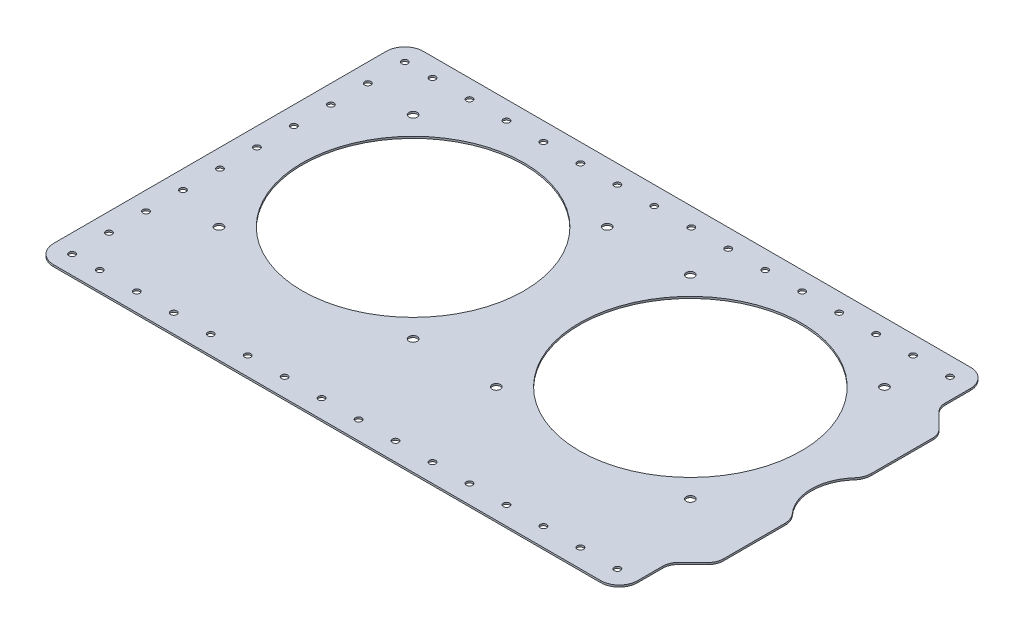
from build123d import *

# Parameters (mm, degrees)
SKETCH1_W                      = 329
SKETCH1_H                      = 200
BOSS_EXTRUDE1_DEPTH            = 1
CUT_EXTRUDE1_DEPTH             = 2
FILLET1_R                      = 8
FILLET2_R                      = 10
SKETCH3_R                      = 1.7
CUT_EXTRUDE2_DEPTH             = 2
M3_CLEARANCE_HOLE1_AT_2_COUNT  = 2
M3_CLEARANCE_HOLE1_AT_2_PITCH  = 20
M3_CLEARANCE_HOLE1_AT_3_COUNT  = 2
M3_CLEARANCE_HOLE1_AT_3_PITCH  = 40
M3_CLEARANCE_HOLE1_AT_4_COUNT  = 2
M3_CLEARANCE_HOLE1_AT_4_PITCH  = 60
M3_CLEARANCE_HOLE1_AT_5_COUNT  = 2
M3_CLEARANCE_HOLE1_AT_5_PITCH  = 80
M3_CLEARANCE_HOLE1_AT_6_COUNT  = 2
M3_CLEARANCE_HOLE1_AT_6_PITCH  = 100
M3_CLEARANCE_HOLE1_AT_7_COUNT  = 2
M3_CLEARANCE_HOLE1_AT_7_PITCH  = 120
M3_CLEARANCE_HOLE2_AT_2_COUNT  = 2
M3_CLEARANCE_HOLE2_AT_2_PITCH  = 20
M3_CLEARANCE_HOLE2_AT_3_COUNT  = 2
M3_CLEARANCE_HOLE2_AT_3_PITCH  = 40
M3_CLEARANCE_HOLE2_AT_4_COUNT  = 2
M3_CLEARANCE_HOLE2_AT_4_PITCH  = 60
M3_CLEARANCE_HOLE2_AT_5_COUNT  = 2
M3_CLEARANCE_HOLE2_AT_5_PITCH  = 80
M3_CLEARANCE_HOLE2_AT_6_COUNT  = 2
M3_CLEARANCE_HOLE2_AT_6_PITCH  = 100
M3_CLEARANCE_HOLE2_AT_7_COUNT  = 2
M3_CLEARANCE_HOLE2_AT_7_PITCH  = 120
M3_CLEARANCE_HOLE2_AT_8_COUNT  = 2
M3_CLEARANCE_HOLE2_AT_8_PITCH  = 140
M3_CLEARANCE_HOLE2_AT_9_COUNT  = 2
M3_CLEARANCE_HOLE2_AT_9_PITCH  = 160
M3_CLEARANCE_HOLE2_AT_10_COUNT = 2
M3_CLEARANCE_HOLE2_AT_10_PITCH = 180
M3_CLEARANCE_HOLE2_AT_11_COUNT = 2
M3_CLEARANCE_HOLE2_AT_11_PITCH = 200
M3_CLEARANCE_HOLE2_AT_12_COUNT = 2
M3_CLEARANCE_HOLE2_AT_12_PITCH = 220
M3_CLEARANCE_HOLE2_AT_13_COUNT = 2
M3_CLEARANCE_HOLE2_AT_13_PITCH = 240
M3_CLEARANCE_HOLE2_AT_14_COUNT = 2
M3_CLEARANCE_HOLE2_AT_14_PITCH = 260
M3_CLEARANCE_HOLE2_AT_15_COUNT = 2
M3_CLEARANCE_HOLE2_AT_15_PITCH = 280
M3_CLEARANCE_HOLE2_AT_16_COUNT = 2
M3_CLEARANCE_HOLE2_AT_16_PITCH = 332.866339542
M3_CLEARANCE_HOLE2_AT_17_COUNT = 2
M3_CLEARANCE_HOLE2_AT_17_PITCH = 316.227766017
M3_CLEARANCE_HOLE2_AT_18_COUNT = 2
M3_CLEARANCE_HOLE2_AT_18_PITCH = 300
M3_CLEARANCE_HOLE2_AT_19_COUNT = 2
M3_CLEARANCE_HOLE2_AT_19_PITCH = 284.253408071
M3_CLEARANCE_HOLE2_AT_20_COUNT = 2
M3_CLEARANCE_HOLE2_AT_20_PITCH = 269.072480941
M3_CLEARANCE_HOLE2_AT_21_COUNT = 2
M3_CLEARANCE_HOLE2_AT_21_PITCH = 254.558441227
M3_CLEARANCE_HOLE2_AT_22_COUNT = 2
M3_CLEARANCE_HOLE2_AT_22_PITCH = 240.831891576
M3_CLEARANCE_HOLE2_AT_23_COUNT = 2
M3_CLEARANCE_HOLE2_AT_23_PITCH = 228.03508502
M3_CLEARANCE_HOLE2_AT_24_COUNT = 2
M3_CLEARANCE_HOLE2_AT_24_PITCH = 216.333076528
M3_CLEARANCE_HOLE2_AT_25_COUNT = 2
M3_CLEARANCE_HOLE2_AT_25_PITCH = 205.91260282
M3_CLEARANCE_HOLE2_AT_26_COUNT = 2
M3_CLEARANCE_HOLE2_AT_26_PITCH = 196.977156036
M3_CLEARANCE_HOLE2_AT_27_COUNT = 2
M3_CLEARANCE_HOLE2_AT_27_PITCH = 189.73665961
M3_CLEARANCE_HOLE2_AT_28_COUNT = 2
M3_CLEARANCE_HOLE2_AT_28_PITCH = 184.390889146
M3_CLEARANCE_HOLE2_AT_29_COUNT = 2
M3_CLEARANCE_HOLE2_AT_29_PITCH = 181.107702763
M3_CLEARANCE_HOLE2_AT_30_COUNT = 2
M3_CLEARANCE_HOLE2_AT_30_PITCH = 180
SKETCH9_R                      = 25
CUT_EXTRUDE3_DEPTH             = 10
FILLET3_R                      = 10
M4_CLEARANCE_HOLE1_AT_2_COUNT  = 2
M4_CLEARANCE_HOLE1_AT_2_PITCH  = 183.098334236
M4_CLEARANCE_HOLE1_AT_3_COUNT  = 2
M4_CLEARANCE_HOLE1_AT_3_PITCH  = 255
M4_CLEARANCE_HOLE1_AT_4_COUNT  = 2
M4_CLEARANCE_HOLE1_AT_4_PITCH  = 275.771644663
M4_CLEARANCE_HOLE1_AT_5_COUNT  = 2
M4_CLEARANCE_HOLE1_AT_5_PITCH  = 150
M4_CLEARANCE_HOLE1_AT_6_COUNT  = 2
M4_CLEARANCE_HOLE1_AT_6_PITCH  = 105
M4_CLEARANCE_HOLE1_AT_7_COUNT  = 2
M4_CLEARANCE_HOLE1_AT_7_PITCH  = 148.492424049
M4_CLEARANCE_HOLE1_AT_8_COUNT  = 2
M4_CLEARANCE_HOLE1_AT_8_PITCH  = 105
SKETCH12_R                     = 60
CUT_EXTRUDE4_DEPTH             = 10


with BuildPart() as part:
    # Sketch1 → Boss-Extrude1 (new body)
    with BuildSketch(Plane(origin=(0, 0, 0), x_dir=(1, 0, 0), z_dir=(0, 1, 0))):
        Rectangle(SKETCH1_W, SKETCH1_H)
    extrude(amount=BOSS_EXTRUDE1_DEPTH)

    # Sketch2 → Cut-Extrude1 (cut, through all)
    with BuildSketch(Plane(origin=(0, 0, 0), x_dir=(-1, 0, 0), z_dir=(0, -1, 0))):
        Polygon((-164.5, -60), (-151.5, -73), (-151.5, -100), (-164.5, -100), align=None)
        Polygon((-151.5, 100), (-164.5, 100), (-164.5, 60), (-151.5, 73), align=None)
    extrude(amount=-CUT_EXTRUDE1_DEPTH, mode=Mode.SUBTRACT)

    # Fillet1
    fillet1_edges = [part.edges().sort_by_distance(p)[0] for p in [
        (164.5, 0.5, 60),
        (151.5, 0.5, 73),
        (151.5, 0.5, -73),
        (164.5, 0.5, -60),
    ]]
    fillet(fillet1_edges, radius=FILLET1_R)

    # Fillet2
    fillet2_edges = [part.edges().sort_by_distance(p)[0] for p in [
        (151.5, 0.5, 100),
        (151.5, 0.5, -100),
        (-164.5, 0.5, 100),
        (-164.5, 0.5, -100),
    ]]
    fillet(fillet2_edges, radius=FILLET2_R)

    # Sketch3 → Cut-Extrude2 (cut, through all)
    with BuildSketch(Plane.XZ):
        with Locations((-154.5, -70)):
            Circle(SKETCH3_R)
        with Locations((-154.5, -90)):
            Circle(SKETCH3_R)
        with Locations((-154.5, 70)):
            Circle(SKETCH3_R)
        with Locations((-154.5, 90)):
            Circle(SKETCH3_R)
    extrude(amount=-CUT_EXTRUDE2_DEPTH, mode=Mode.SUBTRACT)

    # Sketch6 → M3 Clearance Hole1 (revolve, cut)
    with BuildSketch(Plane(origin=(-154.5, 0, 70), x_dir=(0, 0, -1), z_dir=(1, 0, 0))):
        Polygon((0, 0), (0, 1), (1.7, 1), (1.7, 0.025), (1.725, 0), align=None)
    m3_clearance_hole1 = revolve(axis=Axis((-154.5, -6.35, 70), (0, 1, 0)), mode=Mode.SUBTRACT)

    # M3 Clearance Hole1 at 2: M3 Clearance Hole1 ×2
    with Locations(*[(0, 0, -i * M3_CLEARANCE_HOLE1_AT_2_PITCH) for i in range(1, M3_CLEARANCE_HOLE1_AT_2_COUNT)]):
        add(m3_clearance_hole1, mode=Mode.SUBTRACT)

    # M3 Clearance Hole1 at 3: M3 Clearance Hole1 ×2
    with Locations(*[(0, 0, -i * M3_CLEARANCE_HOLE1_AT_3_PITCH) for i in range(1, M3_CLEARANCE_HOLE1_AT_3_COUNT)]):
        add(m3_clearance_hole1, mode=Mode.SUBTRACT)

    # M3 Clearance Hole1 at 4: M3 Clearance Hole1 ×2
    with Locations(*[(0, 0, -i * M3_CLEARANCE_HOLE1_AT_4_PITCH) for i in range(1, M3_CLEARANCE_HOLE1_AT_4_COUNT)]):
        add(m3_clearance_hole1, mode=Mode.SUBTRACT)

    # M3 Clearance Hole1 at 5: M3 Clearance Hole1 ×2
    with Locations(*[(0, 0, -i * M3_CLEARANCE_HOLE1_AT_5_PITCH) for i in range(1, M3_CLEARANCE_HOLE1_AT_5_COUNT)]):
        add(m3_clearance_hole1, mode=Mode.SUBTRACT)

    # M3 Clearance Hole1 at 6: M3 Clearance Hole1 ×2
    with Locations(*[(0, 0, -i * M3_CLEARANCE_HOLE1_AT_6_PITCH) for i in range(1, M3_CLEARANCE_HOLE1_AT_6_COUNT)]):
        add(m3_clearance_hole1, mode=Mode.SUBTRACT)

    # M3 Clearance Hole1 at 7: M3 Clearance Hole1 ×2
    with Locations(*[(0, 0, -i * M3_CLEARANCE_HOLE1_AT_7_PITCH) for i in range(1, M3_CLEARANCE_HOLE1_AT_7_COUNT)]):
        add(m3_clearance_hole1, mode=Mode.SUBTRACT)

    # Sketch8 → M3 Clearance Hole2 (revolve, cut)
    with BuildSketch(Plane(origin=(140.5, 0, -90), x_dir=(0, 0, -1), z_dir=(1, 0, 0))):
        Polygon((0, 0), (0, 1), (1.7, 1), (1.7, 0.025), (1.725, 0), align=None)
    m3_clearance_hole2 = revolve(axis=Axis((140.5, -6.35, -90), (0, 1, 0)), mode=Mode.SUBTRACT)

    # M3 Clearance Hole2 at 2: M3 Clearance Hole2 ×2
    with Locations(*[(-i * M3_CLEARANCE_HOLE2_AT_2_PITCH, 0, 0) for i in range(1, M3_CLEARANCE_HOLE2_AT_2_COUNT)]):
        add(m3_clearance_hole2, mode=Mode.SUBTRACT)

    # M3 Clearance Hole2 at 3: M3 Clearance Hole2 ×2
    with Locations(*[(-i * M3_CLEARANCE_HOLE2_AT_3_PITCH, 0, 0) for i in range(1, M3_CLEARANCE_HOLE2_AT_3_COUNT)]):
        add(m3_clearance_hole2, mode=Mode.SUBTRACT)

    # M3 Clearance Hole2 at 4: M3 Clearance Hole2 ×2
    with Locations(*[(-i * M3_CLEARANCE_HOLE2_AT_4_PITCH, 0, 0) for i in range(1, M3_CLEARANCE_HOLE2_AT_4_COUNT)]):
        add(m3_clearance_hole2, mode=Mode.SUBTRACT)

    # M3 Clearance Hole2 at 5: M3 Clearance Hole2 ×2
    with Locations(*[(-i * M3_CLEARANCE_HOLE2_AT_5_PITCH, 0, 0) for i in range(1, M3_CLEARANCE_HOLE2_AT_5_COUNT)]):
        add(m3_clearance_hole2, mode=Mode.SUBTRACT)

    # M3 Clearance Hole2 at 6: M3 Clearance Hole2 ×2
    with Locations(*[(-i * M3_CLEARANCE_HOLE2_AT_6_PITCH, 0, 0) for i in range(1, M3_CLEARANCE_HOLE2_AT_6_COUNT)]):
        add(m3_clearance_hole2, mode=Mode.SUBTRACT)

    # M3 Clearance Hole2 at 7: M3 Clearance Hole2 ×2
    with Locations(*[(-i * M3_CLEARANCE_HOLE2_AT_7_PITCH, 0, 0) for i in range(1, M3_CLEARANCE_HOLE2_AT_7_COUNT)]):
        add(m3_clearance_hole2, mode=Mode.SUBTRACT)

    # M3 Clearance Hole2 at 8: M3 Clearance Hole2 ×2
    with Locations(*[(-i * M3_CLEARANCE_HOLE2_AT_8_PITCH, 0, 0) for i in range(1, M3_CLEARANCE_HOLE2_AT_8_COUNT)]):
        add(m3_clearance_hole2, mode=Mode.SUBTRACT)

    # M3 Clearance Hole2 at 9: M3 Clearance Hole2 ×2
    with Locations(*[(-i * M3_CLEARANCE_HOLE2_AT_9_PITCH, 0, 0) for i in range(1, M3_CLEARANCE_HOLE2_AT_9_COUNT)]):
        add(m3_clearance_hole2, mode=Mode.SUBTRACT)

    # M3 Clearance Hole2 at 10: M3 Clearance Hole2 ×2
    with Locations(*[(-i * M3_CLEARANCE_HOLE2_AT_10_PITCH, 0, 0) for i in range(1, M3_CLEARANCE_HOLE2_AT_10_COUNT)]):
        add(m3_clearance_hole2, mode=Mode.SUBTRACT)

    # M3 Clearance Hole2 at 11: M3 Clearance Hole2 ×2
    with Locations(*[(-i * M3_CLEARANCE_HOLE2_AT_11_PITCH, 0, 0) for i in range(1, M3_CLEARANCE_HOLE2_AT_11_COUNT)]):
        add(m3_clearance_hole2, mode=Mode.SUBTRACT)

    # M3 Clearance Hole2 at 12: M3 Clearance Hole2 ×2
    with Locations(*[(-i * M3_CLEARANCE_HOLE2_AT_12_PITCH, 0, 0) for i in range(1, M3_CLEARANCE_HOLE2_AT_12_COUNT)]):
        add(m3_clearance_hole2, mode=Mode.SUBTRACT)

    # M3 Clearance Hole2 at 13: M3 Clearance Hole2 ×2
    with Locations(*[(-i * M3_CLEARANCE_HOLE2_AT_13_PITCH, 0, 0) for i in range(1, M3_CLEARANCE_HOLE2_AT_13_COUNT)]):
        add(m3_clearance_hole2, mode=Mode.SUBTRACT)

    # M3 Clearance Hole2 at 14: M3 Clearance Hole2 ×2
    with Locations(*[(-i * M3_CLEARANCE_HOLE2_AT_14_PITCH, 0, 0) for i in range(1, M3_CLEARANCE_HOLE2_AT_14_COUNT)]):
        add(m3_clearance_hole2, mode=Mode.SUBTRACT)

    # M3 Clearance Hole2 at 15: M3 Clearance Hole2 ×2
    with Locations(*[(-i * M3_CLEARANCE_HOLE2_AT_15_PITCH, 0, 0) for i in range(1, M3_CLEARANCE_HOLE2_AT_15_COUNT)]):
        add(m3_clearance_hole2, mode=Mode.SUBTRACT)

    # M3 Clearance Hole2 at 16: M3 Clearance Hole2 ×2
    with Locations(*[Vector(-0.841178475, 0, 0.540757591) * (i * M3_CLEARANCE_HOLE2_AT_16_PITCH) for i in range(1, M3_CLEARANCE_HOLE2_AT_16_COUNT)]):
        add(m3_clearance_hole2, mode=Mode.SUBTRACT)

    # M3 Clearance Hole2 at 17: M3 Clearance Hole2 ×2
    with Locations(*[Vector(-0.822192192, 0, 0.569209979) * (i * M3_CLEARANCE_HOLE2_AT_17_PITCH) for i in range(1, M3_CLEARANCE_HOLE2_AT_17_COUNT)]):
        add(m3_clearance_hole2, mode=Mode.SUBTRACT)

    # M3 Clearance Hole2 at 18: M3 Clearance Hole2 ×2
    with Locations(*[Vector(-0.8, 0, 0.6) * (i * M3_CLEARANCE_HOLE2_AT_18_PITCH) for i in range(1, M3_CLEARANCE_HOLE2_AT_18_COUNT)]):
        add(m3_clearance_hole2, mode=Mode.SUBTRACT)

    # M3 Clearance Hole2 at 19: M3 Clearance Hole2 ×2
    with Locations(*[Vector(-0.773957299, 0, 0.63323779) * (i * M3_CLEARANCE_HOLE2_AT_19_PITCH) for i in range(1, M3_CLEARANCE_HOLE2_AT_19_COUNT)]):
        add(m3_clearance_hole2, mode=Mode.SUBTRACT)

    # M3 Clearance Hole2 at 20: M3 Clearance Hole2 ×2
    with Locations(*[Vector(-0.743294146, 0, 0.668964732) * (i * M3_CLEARANCE_HOLE2_AT_20_PITCH) for i in range(1, M3_CLEARANCE_HOLE2_AT_20_COUNT)]):
        add(m3_clearance_hole2, mode=Mode.SUBTRACT)

    # M3 Clearance Hole2 at 21: M3 Clearance Hole2 ×2
    with Locations(*[Vector(-0.707106781, 0, 0.707106781) * (i * M3_CLEARANCE_HOLE2_AT_21_PITCH) for i in range(1, M3_CLEARANCE_HOLE2_AT_21_COUNT)]):
        add(m3_clearance_hole2, mode=Mode.SUBTRACT)

    # M3 Clearance Hole2 at 22: M3 Clearance Hole2 ×2
    with Locations(*[Vector(-0.664363839, 0, 0.747409319) * (i * M3_CLEARANCE_HOLE2_AT_22_PITCH) for i in range(1, M3_CLEARANCE_HOLE2_AT_22_COUNT)]):
        add(m3_clearance_hole2, mode=Mode.SUBTRACT)

    # M3 Clearance Hole2 at 23: M3 Clearance Hole2 ×2
    with Locations(*[Vector(-0.613940614, 0, 0.789352217) * (i * M3_CLEARANCE_HOLE2_AT_23_PITCH) for i in range(1, M3_CLEARANCE_HOLE2_AT_23_COUNT)]):
        add(m3_clearance_hole2, mode=Mode.SUBTRACT)

    # M3 Clearance Hole2 at 24: M3 Clearance Hole2 ×2
    with Locations(*[Vector(-0.554700196, 0, 0.832050294) * (i * M3_CLEARANCE_HOLE2_AT_24_PITCH) for i in range(1, M3_CLEARANCE_HOLE2_AT_24_COUNT)]):
        add(m3_clearance_hole2, mode=Mode.SUBTRACT)

    # M3 Clearance Hole2 at 25: M3 Clearance Hole2 ×2
    with Locations(*[Vector(-0.485642931, 0, 0.874157276) * (i * M3_CLEARANCE_HOLE2_AT_25_PITCH) for i in range(1, M3_CLEARANCE_HOLE2_AT_25_COUNT)]):
        add(m3_clearance_hole2, mode=Mode.SUBTRACT)

    # M3 Clearance Hole2 at 26: M3 Clearance Hole2 ×2
    with Locations(*[Vector(-0.406138466, 0, 0.913811549) * (i * M3_CLEARANCE_HOLE2_AT_26_PITCH) for i in range(1, M3_CLEARANCE_HOLE2_AT_26_COUNT)]):
        add(m3_clearance_hole2, mode=Mode.SUBTRACT)

    # M3 Clearance Hole2 at 27: M3 Clearance Hole2 ×2
    with Locations(*[Vector(-0.316227766, 0, 0.948683298) * (i * M3_CLEARANCE_HOLE2_AT_27_PITCH) for i in range(1, M3_CLEARANCE_HOLE2_AT_27_COUNT)]):
        add(m3_clearance_hole2, mode=Mode.SUBTRACT)

    # M3 Clearance Hole2 at 28: M3 Clearance Hole2 ×2
    with Locations(*[Vector(-0.216930458, 0, 0.97618706) * (i * M3_CLEARANCE_HOLE2_AT_28_PITCH) for i in range(1, M3_CLEARANCE_HOLE2_AT_28_COUNT)]):
        add(m3_clearance_hole2, mode=Mode.SUBTRACT)

    # M3 Clearance Hole2 at 29: M3 Clearance Hole2 ×2
    with Locations(*[Vector(-0.110431526, 0, 0.993883735) * (i * M3_CLEARANCE_HOLE2_AT_29_PITCH) for i in range(1, M3_CLEARANCE_HOLE2_AT_29_COUNT)]):
        add(m3_clearance_hole2, mode=Mode.SUBTRACT)

    # M3 Clearance Hole2 at 30: M3 Clearance Hole2 ×2
    with Locations(*[(0, 0, i * M3_CLEARANCE_HOLE2_AT_30_PITCH) for i in range(1, M3_CLEARANCE_HOLE2_AT_30_COUNT)]):
        add(m3_clearance_hole2, mode=Mode.SUBTRACT)

    # Sketch9 → Cut-Extrude3 (cut)
    with BuildSketch(Plane(origin=(0, 0, 0), x_dir=(-1, 0, 0), z_dir=(0, -1, 0))):
        with Locations((-180.5, 0)):
            Circle(SKETCH9_R)
    extrude(amount=-CUT_EXTRUDE3_DEPTH, mode=Mode.SUBTRACT)

    # Fillet3
    fillet3_edges = [part.edges().sort_by_distance(p)[0] for p in [
        (164.5, 0.5, -19.209372712),
        (164.5, 0.5, 19.209372712),
    ]]
    fillet(fillet3_edges, radius=FILLET3_R)

    # Sketch11 → M4 Clearance Hole1 (revolve, cut)
    with BuildSketch(Plane(origin=(127.5, 0, 37.5), x_dir=(0, 0, -1), z_dir=(1, 0, 0))):
        Polygon((0, 0), (0, 1), (2.25, 1), (2.25, 0.025), (2.275, 0), align=None)
    m4_clearance_hole1 = revolve(axis=Axis((127.5, -6.35, 37.5), (0, 1, 0)), mode=Mode.SUBTRACT)

    # M4 Clearance Hole1 at 2: M4 Clearance Hole1 ×2
    with Locations(*[Vector(-0.819231921, 0, -0.573462344) * (i * M4_CLEARANCE_HOLE1_AT_2_PITCH) for i in range(1, M4_CLEARANCE_HOLE1_AT_2_COUNT)]):
        add(m4_clearance_hole1, mode=Mode.SUBTRACT)

    # M4 Clearance Hole1 at 3: M4 Clearance Hole1 ×2
    with Locations(*[(-i * M4_CLEARANCE_HOLE1_AT_3_PITCH, 0, 0) for i in range(1, M4_CLEARANCE_HOLE1_AT_3_COUNT)]):
        add(m4_clearance_hole1, mode=Mode.SUBTRACT)

    # M4 Clearance Hole1 at 4: M4 Clearance Hole1 ×2
    with Locations(*[Vector(-0.924678098, 0, -0.380749805) * (i * M4_CLEARANCE_HOLE1_AT_4_PITCH) for i in range(1, M4_CLEARANCE_HOLE1_AT_4_COUNT)]):
        add(m4_clearance_hole1, mode=Mode.SUBTRACT)

    # M4 Clearance Hole1 at 5: M4 Clearance Hole1 ×2
    with Locations(*[(-i * M4_CLEARANCE_HOLE1_AT_5_PITCH, 0, 0) for i in range(1, M4_CLEARANCE_HOLE1_AT_5_COUNT)]):
        add(m4_clearance_hole1, mode=Mode.SUBTRACT)

    # M4 Clearance Hole1 at 6: M4 Clearance Hole1 ×2
    with Locations(*[(0, 0, -i * M4_CLEARANCE_HOLE1_AT_6_PITCH) for i in range(1, M4_CLEARANCE_HOLE1_AT_6_COUNT)]):
        add(m4_clearance_hole1, mode=Mode.SUBTRACT)

    # M4 Clearance Hole1 at 7: M4 Clearance Hole1 ×2
    with Locations(*[Vector(-0.707106781, 0, -0.707106781) * (i * M4_CLEARANCE_HOLE1_AT_7_PITCH) for i in range(1, M4_CLEARANCE_HOLE1_AT_7_COUNT)]):
        add(m4_clearance_hole1, mode=Mode.SUBTRACT)

    # M4 Clearance Hole1 at 8: M4 Clearance Hole1 ×2
    with Locations(*[(-i * M4_CLEARANCE_HOLE1_AT_8_PITCH, 0, 0) for i in range(1, M4_CLEARANCE_HOLE1_AT_8_COUNT)]):
        add(m4_clearance_hole1, mode=Mode.SUBTRACT)

    # Sketch12 → Cut-Extrude4 (cut)
    with BuildSketch(Plane(origin=(0, 0, 0), x_dir=(-1, 0, 0), z_dir=(0, -1, 0))):
        with Locations((75, 15)):
            Circle(SKETCH12_R)
        with Locations((-75, 15)):
            Circle(SKETCH12_R)
    extrude(amount=-CUT_EXTRUDE4_DEPTH, mode=Mode.SUBTRACT)


solid = part.part
